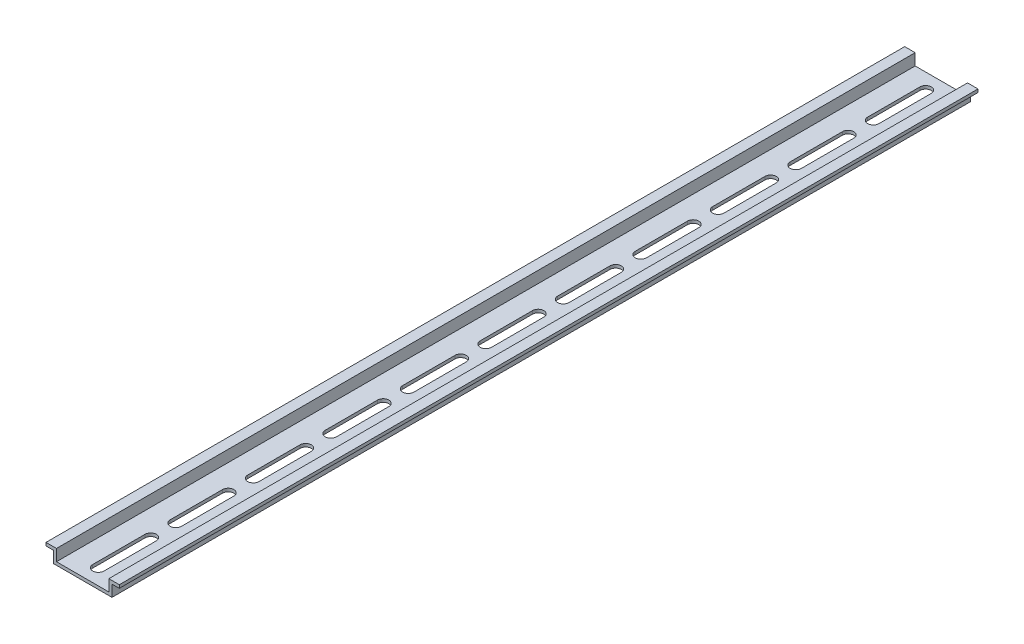
from build123d import *

# Parameters (mm, degrees)
CROQUIS1_W              = 35
CROQUIS1_H              = 410
SALIENTE_EXTRUIR1_DEPTH = 7
CROQUIS2_W              = 25
CROQUIS2_H              = 5.5
CORTAR_EXTRUIR1_DEPTH   = 411
CROQUIS3_W              = 3.5
CROQUIS3_H              = 5.5
CORTAR_EXTRUIR2_DEPTH   = 411
CROQUIS4_W              = 3.5
CROQUIS4_H              = 5.5
CORTAR_EXTRUIR3_DEPTH   = 411
CORTAR_EXTRUIR4_DEPTH   = 2.5
CORTAR_EXTRUIR5_DEPTH   = 2.5
CORTAR_EXTRUIR6_DEPTH   = 2.5
CORTAR_EXTRUIR7_DEPTH   = 2.5
CORTAR_EXTRUIR8_DEPTH   = 2.5
CORTAR_EXTRUIR9_DEPTH   = 2.5
CORTAR_EXTRUIR10_DEPTH  = 2.5
CORTAR_EXTRUIR11_DEPTH  = 2.5
CORTAR_EXTRUIR12_DEPTH  = 2.5
CORTAR_EXTRUIR13_DEPTH  = 2.5
CORTAR_EXTRUIR14_DEPTH  = 8


with BuildPart() as part:
    # Croquis1 → Saliente-Extruir1 (new body)
    with BuildSketch(Plane.XZ.offset(1.5)):
        with Locations((0, 205)):
            Rectangle(CROQUIS1_W, CROQUIS1_H)
    extrude(amount=-SALIENTE_EXTRUIR1_DEPTH)

    # Croquis2 → Cortar-Extruir1 (cut, through all)
    with BuildSketch(Plane.XY.offset(410)):
        with Locations((0, 2.75)):
            Rectangle(CROQUIS2_W, CROQUIS2_H)
    extrude(amount=-CORTAR_EXTRUIR1_DEPTH, mode=Mode.SUBTRACT)

    # Croquis3 → Cortar-Extruir2 (cut, through all)
    with BuildSketch(Plane.XY.offset(410)):
        with Locations((15.75, 1.25)):
            Rectangle(CROQUIS3_W, CROQUIS3_H)
    extrude(amount=-CORTAR_EXTRUIR2_DEPTH, mode=Mode.SUBTRACT)

    # Croquis4 → Cortar-Extruir3 (cut, through all)
    with BuildSketch(Plane.XY.offset(410)):
        with Locations((-15.75, 1.25)):
            Rectangle(CROQUIS4_W, CROQUIS4_H)
    extrude(amount=-CORTAR_EXTRUIR3_DEPTH, mode=Mode.SUBTRACT)

    # Croquis5 → Cortar-Extruir4 (cut, through all)
    with BuildSketch(Plane(origin=(0, 0, 0), x_dir=(-1, 0, 0), z_dir=(0, 1, 0))):
        with BuildLine():
            Line((-2.7, 402.5), (-2.7, 377.5))
            ThreePointArc((-2.7, 377.5), (0, 374.8), (2.7, 377.5))
            Line((2.7, 377.5), (2.7, 402.5))
            ThreePointArc((2.7, 402.5), (0, 405.2), (-2.7, 402.5))
        make_face()
    extrude(amount=-CORTAR_EXTRUIR4_DEPTH, mode=Mode.SUBTRACT)

    # Croquis6 → Cortar-Extruir5 (cut, through all)
    with BuildSketch(Plane(origin=(0, 0, 0), x_dir=(-1, 0, 0), z_dir=(0, 1, 0))):
        with BuildLine():
            Line((-2.7, 365.5), (-2.7, 340.5))
            ThreePointArc((-2.7, 340.5), (0, 337.8), (2.7, 340.5))
            Line((2.7, 340.5), (2.7, 365.5))
            ThreePointArc((2.7, 365.5), (0, 368.2), (-2.7, 365.5))
        make_face()
    extrude(amount=-CORTAR_EXTRUIR5_DEPTH, mode=Mode.SUBTRACT)

    # Croquis7 → Cortar-Extruir6 (cut, through all)
    with BuildSketch(Plane(origin=(0, 0, 0), x_dir=(-1, 0, 0), z_dir=(0, 1, 0))):
        with BuildLine():
            Line((-2.7, 328.5), (-2.7, 303.5))
            ThreePointArc((-2.7, 303.5), (0, 300.8), (2.7, 303.5))
            Line((2.7, 303.5), (2.7, 328.5))
            ThreePointArc((2.7, 328.5), (0, 331.2), (-2.7, 328.5))
        make_face()
    extrude(amount=-CORTAR_EXTRUIR6_DEPTH, mode=Mode.SUBTRACT)

    # Croquis8 → Cortar-Extruir7 (cut, through all)
    with BuildSketch(Plane(origin=(0, 0, 0), x_dir=(-1, 0, 0), z_dir=(0, 1, 0))):
        with BuildLine():
            Line((-2.7, 291.5), (-2.7, 266.5))
            ThreePointArc((-2.7, 266.5), (0, 263.8), (2.7, 266.5))
            Line((2.7, 266.5), (2.7, 291.5))
            ThreePointArc((2.7, 291.5), (0, 294.2), (-2.7, 291.5))
        make_face()
    extrude(amount=-CORTAR_EXTRUIR7_DEPTH, mode=Mode.SUBTRACT)

    # Croquis9 → Cortar-Extruir8 (cut, through all)
    with BuildSketch(Plane(origin=(0, 0, 0), x_dir=(-1, 0, 0), z_dir=(0, 1, 0))):
        with BuildLine():
            Line((-2.7, 254.5), (-2.7, 229.5))
            ThreePointArc((-2.7, 229.5), (0, 226.8), (2.7, 229.5))
            Line((2.7, 229.5), (2.7, 254.5))
            ThreePointArc((2.7, 254.5), (0, 257.2), (-2.7, 254.5))
        make_face()
    extrude(amount=-CORTAR_EXTRUIR8_DEPTH, mode=Mode.SUBTRACT)

    # Croquis10 → Cortar-Extruir9 (cut, through all)
    with BuildSketch(Plane(origin=(0, 0, 0), x_dir=(-1, 0, 0), z_dir=(0, 1, 0))):
        with BuildLine():
            Line((-2.7, 217.5), (-2.7, 192.5))
            ThreePointArc((-2.7, 192.5), (0, 189.8), (2.7, 192.5))
            Line((2.7, 192.5), (2.7, 217.5))
            ThreePointArc((2.7, 217.5), (0, 220.2), (-2.7, 217.5))
        make_face()
    extrude(amount=-CORTAR_EXTRUIR9_DEPTH, mode=Mode.SUBTRACT)

    # Croquis11 → Cortar-Extruir10 (cut, through all)
    with BuildSketch(Plane(origin=(0, 0, 0), x_dir=(-1, 0, 0), z_dir=(0, 1, 0))):
        with BuildLine():
            Line((-2.7, 180.5), (-2.7, 155.5))
            ThreePointArc((-2.7, 155.5), (0, 152.8), (2.7, 155.5))
            Line((2.7, 155.5), (2.7, 180.5))
            ThreePointArc((2.7, 180.5), (0, 183.2), (-2.7, 180.5))
        make_face()
    extrude(amount=-CORTAR_EXTRUIR10_DEPTH, mode=Mode.SUBTRACT)

    # Croquis12 → Cortar-Extruir11 (cut, through all)
    with BuildSketch(Plane(origin=(0, 0, 0), x_dir=(-1, 0, 0), z_dir=(0, 1, 0))):
        with BuildLine():
            Line((-2.7, 143.5), (-2.7, 118.5))
            ThreePointArc((-2.7, 118.5), (0, 115.8), (2.7, 118.5))
            Line((2.7, 118.5), (2.7, 143.5))
            ThreePointArc((2.7, 143.5), (0, 146.2), (-2.7, 143.5))
        make_face()
    extrude(amount=-CORTAR_EXTRUIR11_DEPTH, mode=Mode.SUBTRACT)

    # Croquis13 → Cortar-Extruir12 (cut, through all)
    with BuildSketch(Plane(origin=(0, 0, 0), x_dir=(-1, 0, 0), z_dir=(0, 1, 0))):
        with BuildLine():
            Line((-2.7, 106.5), (-2.7, 81.5))
            ThreePointArc((-2.7, 81.5), (0, 78.8), (2.7, 81.5))
            Line((2.7, 81.5), (2.7, 106.5))
            ThreePointArc((2.7, 106.5), (0, 109.2), (-2.7, 106.5))
        make_face()
    extrude(amount=-CORTAR_EXTRUIR12_DEPTH, mode=Mode.SUBTRACT)

    # Croquis14 → Cortar-Extruir13 (cut, through all)
    with BuildSketch(Plane(origin=(0, 0, 0), x_dir=(-1, 0, 0), z_dir=(0, 1, 0))):
        with BuildLine():
            Line((-2.7, 69.5), (-2.7, 44.5))
            ThreePointArc((-2.7, 44.5), (0, 41.8), (2.7, 44.5))
            Line((2.7, 44.5), (2.7, 69.5))
            ThreePointArc((2.7, 69.5), (0, 72.2), (-2.7, 69.5))
        make_face()
    extrude(amount=-CORTAR_EXTRUIR13_DEPTH, mode=Mode.SUBTRACT)

    # Croquis15 → Cortar-Extruir14 (cut, through all)
    with BuildSketch(Plane.XZ.offset(1.5)):
        with BuildLine():
            Line((-2.7, 32.5), (-2.7, 7.5))
            ThreePointArc((-2.7, 7.5), (0, 4.8), (2.7, 7.5))
            Line((2.7, 7.5), (2.7, 32.5))
            ThreePointArc((2.7, 32.5), (0, 35.2), (-2.7, 32.5))
        make_face()
    extrude(amount=-CORTAR_EXTRUIR14_DEPTH, mode=Mode.SUBTRACT)


solid = part.part
